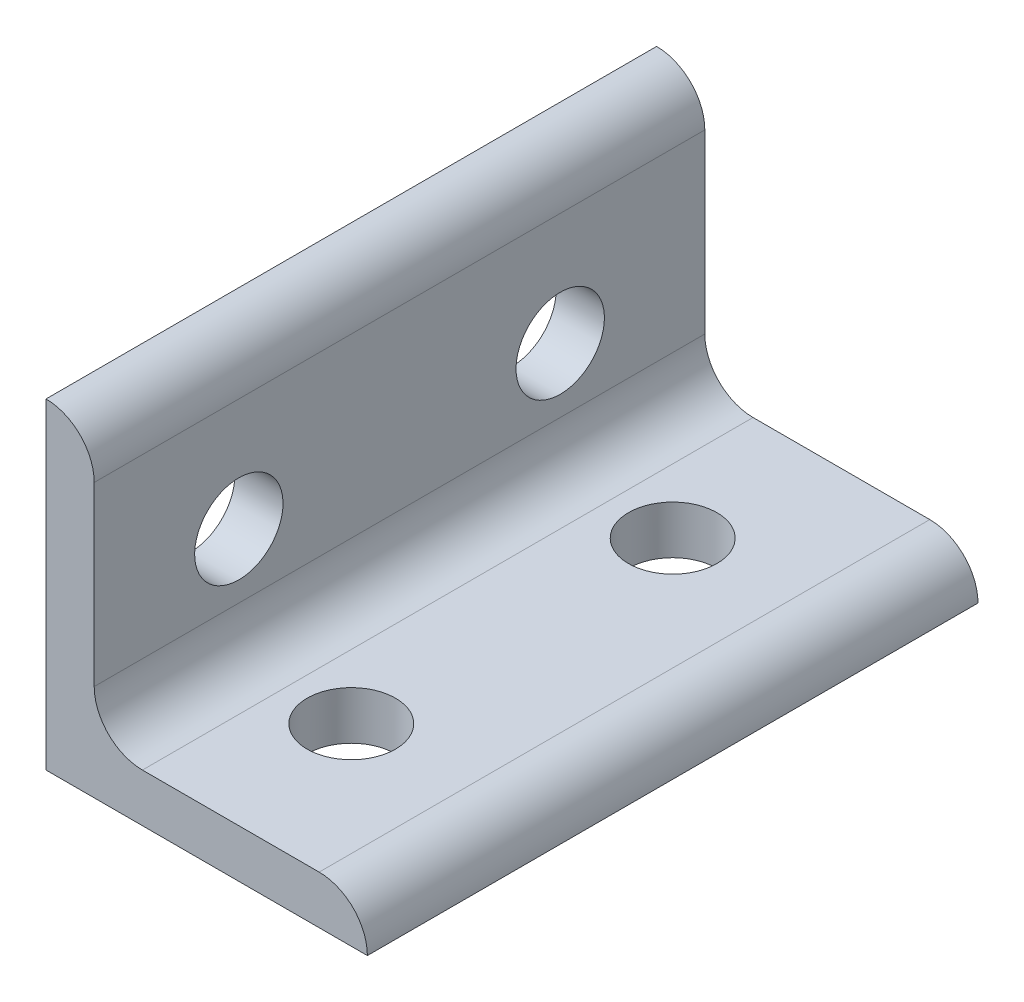
from build123d import *

# Parameters (mm, degrees)
BOSS_EXTRUDE1_DEPTH = 19
SKETCH2_R           = 2.75
CUT_EXTRUDE1_DEPTH  = 21
SKETCH3_R           = 2.75
CUT_EXTRUDE2_DEPTH  = 21


with BuildPart() as part:
    # Sketch1 → Boss-Extrude1 (new body, symmetric)
    with BuildSketch(Plane.XY):
        with BuildLine():
            Line((0, 0), (0, 20))
            ThreePointArc((0, 20), (2.121320344, 19.121320344), (3, 17))
            Line((3, 17), (3, 6))
            ThreePointArc((3, 6), (3.878679656, 3.878679656), (6, 3))
            Line((6, 3), (17, 3))
            ThreePointArc((17, 3), (19.121320344, 2.121320344), (20, 0))
            Line((20, 0), (0, 0))
        make_face()
    extrude(amount=BOSS_EXTRUDE1_DEPTH, both=True)

    # Sketch2 → Cut-Extrude1 (cut, through all)
    with BuildSketch(Plane(origin=(0, 0, 0), x_dir=(1, 0, 0), z_dir=(0, 1, 0))):
        with Locations((10, -10)):
            Circle(SKETCH2_R)
        with Locations((10, 10)):
            Circle(SKETCH2_R)
    extrude(amount=CUT_EXTRUDE1_DEPTH, mode=Mode.SUBTRACT)

    # Sketch3 → Cut-Extrude2 (cut, through all)
    with BuildSketch(Plane(origin=(0, 0, 0), x_dir=(0, 0, -1), z_dir=(1, 0, 0))):
        with Locations((-10, 10)):
            Circle(SKETCH3_R)
        with Locations((10, 10)):
            Circle(SKETCH3_R)
    extrude(amount=CUT_EXTRUDE2_DEPTH, mode=Mode.SUBTRACT)


solid = part.part
